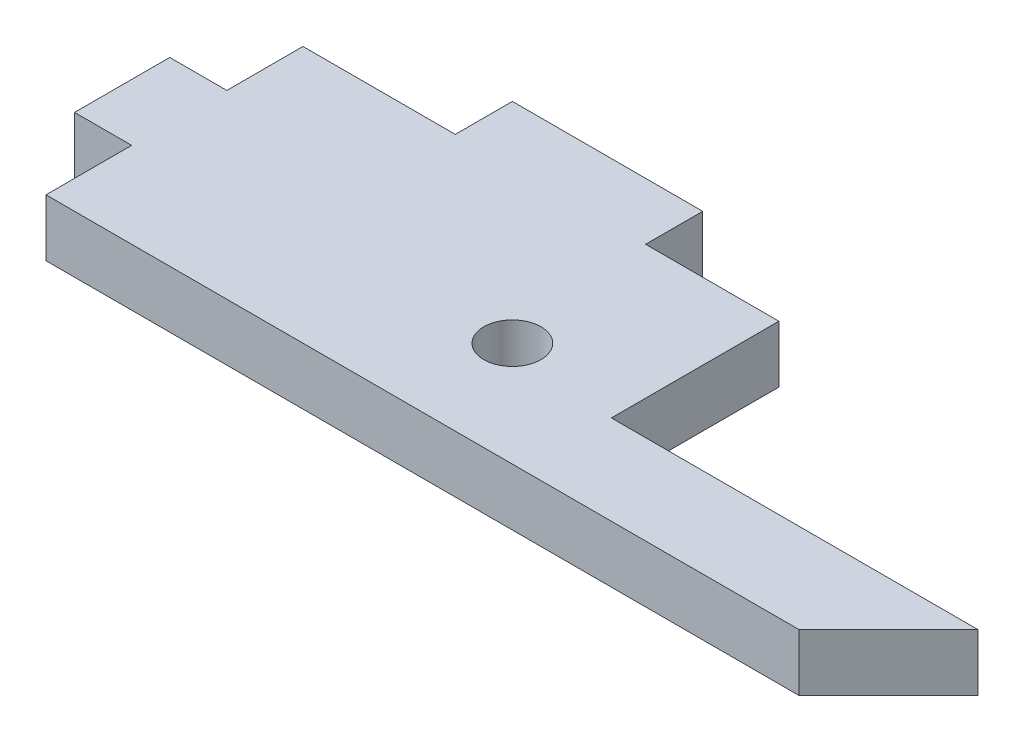
from build123d import *

# Parameters (mm, degrees)
SKETCH1_R           = 1.5
BOSS_EXTRUDE1_DEPTH = 3


with BuildPart() as part:
    # Sketch1 → Boss-Extrude1 (new body)
    with BuildSketch(Plane(origin=(0, 0, 0), x_dir=(1, 0, 0), z_dir=(0, 1, 0))):
        Polygon((-37.889024654, 3.81895344), (-27.889024654, 3.81895344), (-27.889024654, 0.81895344), (-20.889024654, 0.81895344), (-20.889024654, -7.98104656), (-1.629024654, -7.98104656), (-6.329024654, -12.68104656), (-45.889024654, -12.68104656), (-45.889024654, -8.18104656), (-48.889024654, -8.18104656), (-48.889024654, -3.18104656), (-45.889024654, -3.18104656), (-45.889024654, 0.81895344), (-37.889024654, 0.81895344), align=None)
        with Locations((-26.889024654, -7.18104656)):
            Circle(SKETCH1_R, mode=Mode.SUBTRACT)
    extrude(amount=BOSS_EXTRUDE1_DEPTH)


solid = part.part
